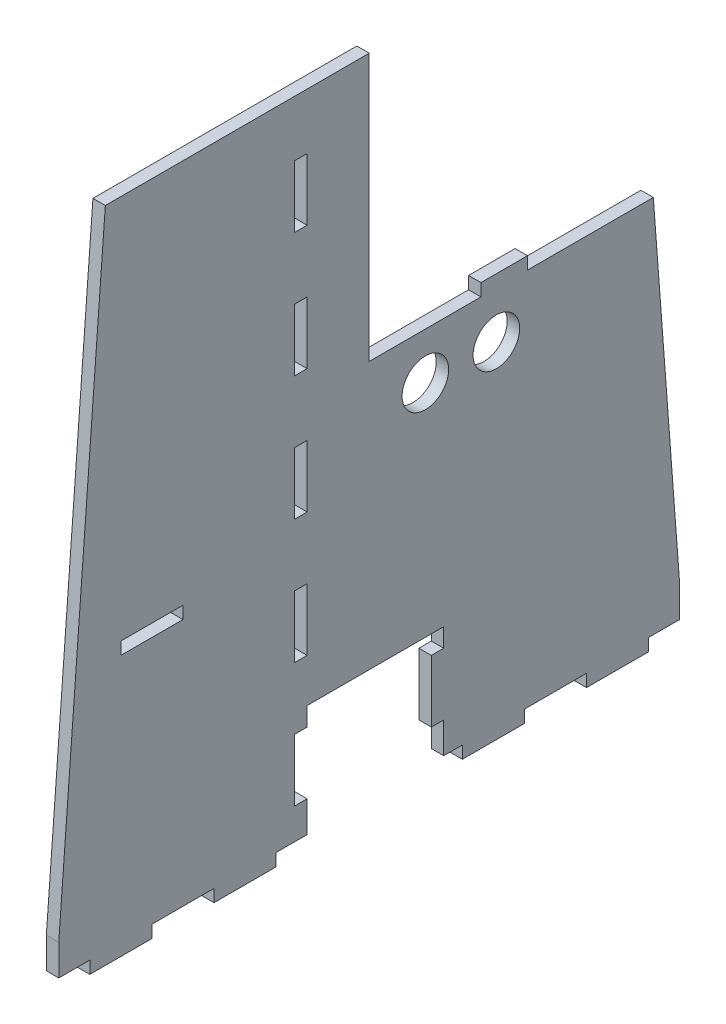
from build123d import *

# Parameters (mm, degrees)
SKICA1_W                = 20
SKICA1_H                = 4
SKICA1_W_2              = 4
SKICA1_H_2              = 20
SKICA1_R                = 7.5
P_IDAT_VYSUNUT_M1_DEPTH = 4


with BuildPart() as part:
    # Skica1 → Přidat vysunutím1 (new body)
    with BuildSketch(Plane(origin=(0, 0, 0), x_dir=(0, 0, -1), z_dir=(1, 0, 0))):
        Polygon((-20, 40), (24, 40), (24, 34), (20, 34), (20, 14), (24, 14), (24, 4), (30, 4), (30, 0), (50, 0), (50, 4), (70, 4), (70, 0), (90, 0), (90, 4), (100, 4), (100, 14), (91.515151515, 126), (51, 126), (51, 130), (36, 130), (36, 126), (0, 126), (0, 212), (-85, 212), (-100, 14), (-100, 4), (-90, 4), (-90, 0), (-70, 0), (-70, 4), (-50, 4), (-50, 0), (-30, 0), (-30, 4), (-20, 4), (-20, 14), (-24, 14), (-24, 34), (-20, 34), align=None)
        with Locations((-70, 86)):
            Rectangle(SKICA1_W, SKICA1_H, mode=Mode.SUBTRACT)
        with Locations((-22, 64)):
            Rectangle(SKICA1_W_2, SKICA1_H_2, mode=Mode.SUBTRACT)
        with Locations((-22, 104)):
            Rectangle(SKICA1_W_2, SKICA1_H_2, mode=Mode.SUBTRACT)
        with Locations((-22, 144)):
            Rectangle(SKICA1_W_2, SKICA1_H_2, mode=Mode.SUBTRACT)
        with Locations((-22, 184)):
            Rectangle(SKICA1_W_2, SKICA1_H_2, mode=Mode.SUBTRACT)
        with Locations((40.95225545, 111)):
            Circle(SKICA1_R, mode=Mode.SUBTRACT)
        with Locations((18.09225545, 111)):
            Circle(SKICA1_R, mode=Mode.SUBTRACT)
    extrude(amount=P_IDAT_VYSUNUT_M1_DEPTH)


solid = part.part
